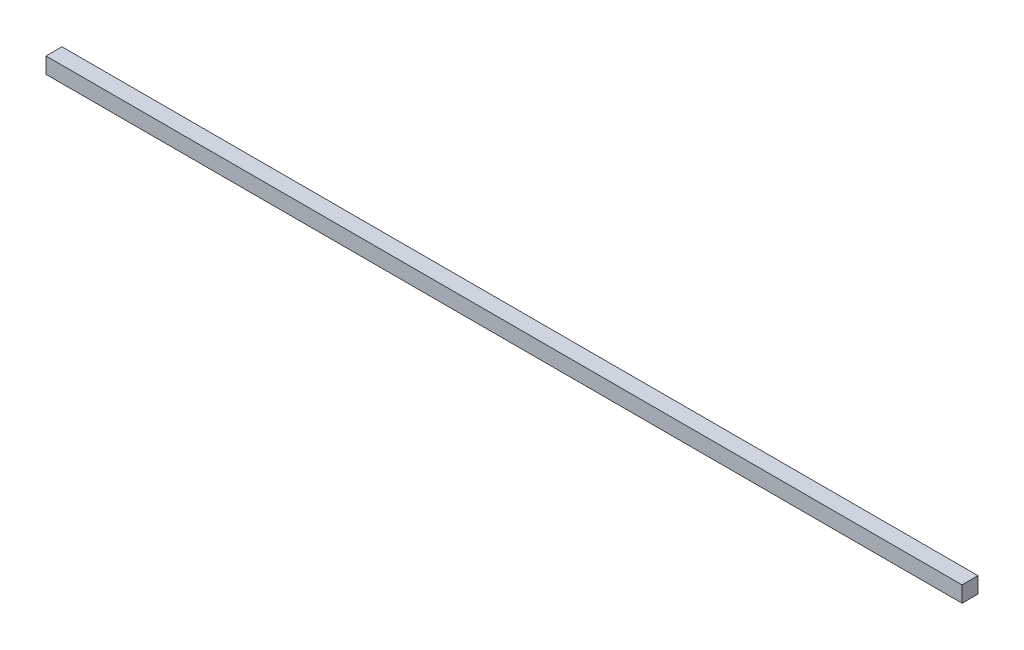
from build123d import *

# Parameters (mm, degrees)
SKETCH_1_W      = 20
SKETCH_1_H      = 20
EXTRUDE_1_DEPTH = 1150


with BuildPart() as part:
    # Эскиз1 → Бобышка-Вытянуть1 (new body)
    with BuildSketch(Plane(origin=(0, 0, 0), x_dir=(0, 0, -1), z_dir=(1, 0, 0))):
        with Locations((10, 10)):
            Rectangle(SKETCH_1_W, SKETCH_1_H)
    extrude(amount=EXTRUDE_1_DEPTH)


solid = part.part
